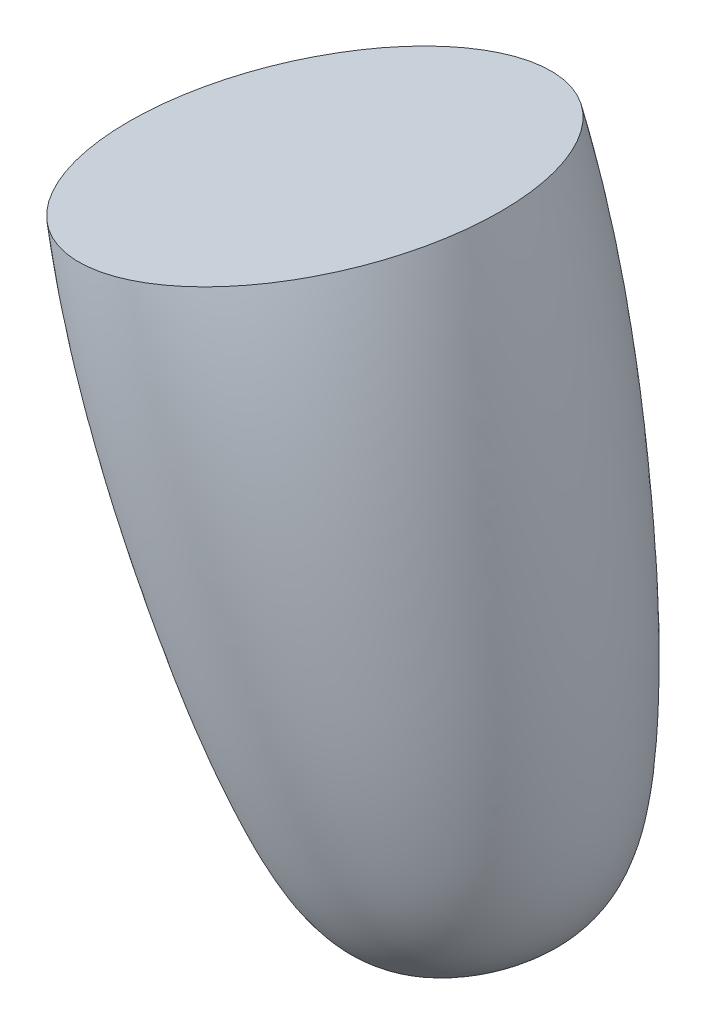
from build123d import *


with BuildPart() as part:
    # Croquis1 → Revolución1 (revolve)
    with BuildSketch(Plane.XY):
        with BuildLine():
            Line((-123.354184704, 35.975126759), (-105.106178469, 41.26759957))
            Line((-105.106178469, 41.26759957), (-88.393106433, -16.357683276))
            add(Edge.make_bspline(
                [(-123.354184704, 35.975126759), (-121.166384307, 25.746216629), (-115.745033919, 10.857533856), (-106.127875765, -9.391515479), (-97.526810031, -20.790890562), (-88.393106433, -16.357683276)],
                knots=[0, 0, 0, 0, 0.457844158, 0.674367665, 1, 1, 1, 1], degree=3))
        make_face()
    revolve(axis=Axis((-105.106178469, 41.26759957, 0), (0.278551201, -0.960421381, 0)))


solid = part.part
